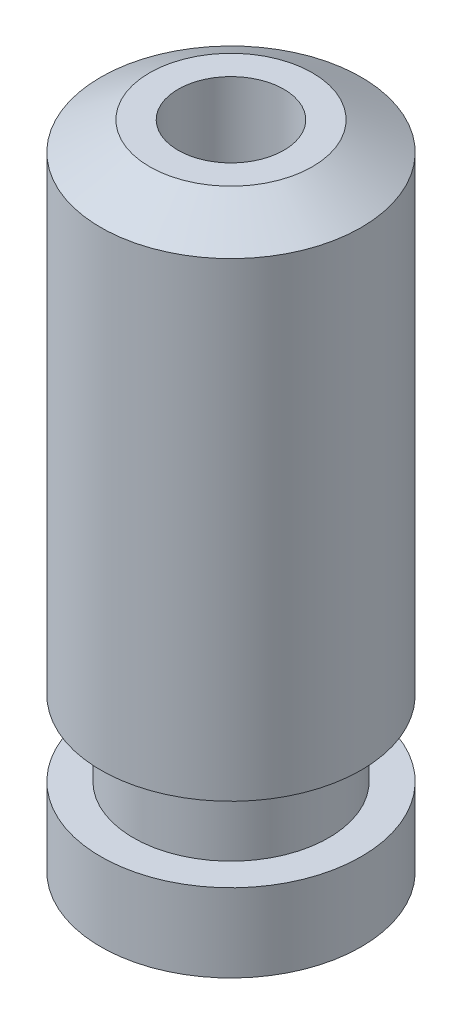
from build123d import *

# Parameters (mm, degrees)
SKETCH3_R          = 3.25
CUT_EXTRUDE1_DEPTH = 41


with BuildPart() as part:
    # Sketch2 → Revolve1 (revolve)
    with BuildSketch(Plane.XY):
        Polygon((0, 0), (8, 0), (8, 4.8), (6, 4.8), (6, 9.4), (8, 9.4), (8, 38.267949192), (5, 40), (0, 40), align=None)
    revolve(axis=Axis((0, 40, 0), (0, -1, 0)))

    # Sketch3 → Cut-Extrude1 (cut, through all)
    with BuildSketch(Plane.XZ):
        Circle(SKETCH3_R)
    extrude(amount=-CUT_EXTRUDE1_DEPTH, mode=Mode.SUBTRACT)


solid = part.part
